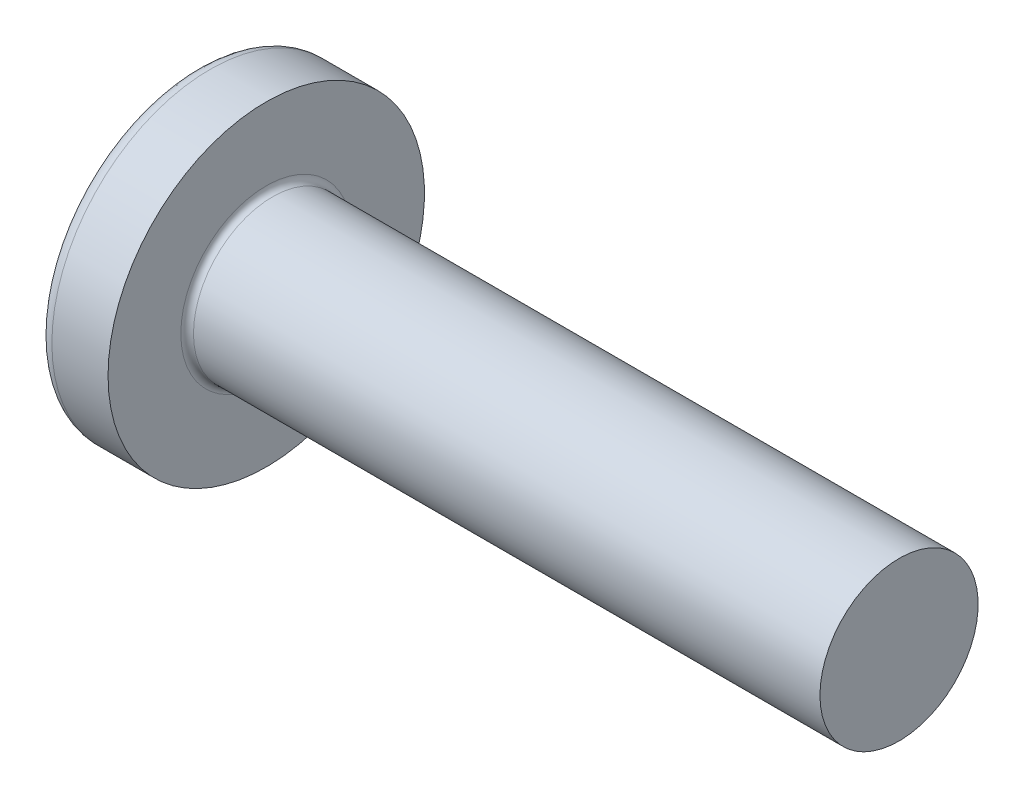
from build123d import *

# Parameters (mm, degrees)
FILLET1_R    = 0.4
SKETCH3_W    = 2.16
SKETCH3_H    = 9.9
SKETCH4_W    = 2.16
SKETCH4_H    = 4.22614225
RECPAT_COUNT = 2
RECPAT_ANGLE = 90


with BuildPart() as part:
    # BodySke → Base-Revolve (revolve)
    with BuildSketch(Plane.XY):
        with BuildLine():
            Line((7.5, 5), (7.5, 10))
            Line((7.5, 10), (3.950103735, 10))
            ThreePointArc((3.950103735, 10), (3.548946469, 9.905650574), (3.231897997, 9.642384106))
            ThreePointArc((3.231897997, 9.642384106), (0.82947542, 5.084799306), (0, 0))
            Line((0, 0), (47.5, 0))
            Line((47.5, 0), (47.5, 5))
            Line((47.5, 5), (7.5, 5))
        make_face()
    revolve(axis=Axis((-25.4, 0, 0), (1, 0, 0)))

    # Fillet1
    fillet1_edges = [part.edges().sort_by_distance(p)[0] for p in [
        (7.5, -5, 0),
    ]]
    fillet(fillet1_edges, radius=FILLET1_R)

    # Sketch3 → Recess section 0
    with BuildSketch(Plane(origin=(0, 0, 0), x_dir=(0, 0, -1), z_dir=(1, 0, 0))):
        Rectangle(SKETCH3_W, SKETCH3_H)
    # Sketch4 → Recess section 1
    with BuildSketch(Plane(origin=(5.69, 0, 0), x_dir=(0, 0, -1), z_dir=(1, 0, 0))):
        Rectangle(SKETCH4_W, SKETCH4_H)
    recess = loft(mode=Mode.SUBTRACT)

    # RecPat: Recess ×2 about axis
    recpat_axis = Axis((0, 0, 0), (1, 0, 0))
    for i in range(1, RECPAT_COUNT):
        add(recess.rotate(recpat_axis, i * RECPAT_ANGLE / (RECPAT_COUNT - 1)), mode=Mode.SUBTRACT)

    # RecCorSke → RecessCore (revolve, cut)
    with BuildSketch(Plane.XY):
        Polygon((0, 0), (0, 2.32838356), (5.69, 1.9305), (6.317257474, 0), align=None)
    revolve(axis=Axis((-3.175, 0, 0), (1, 0, 0)), mode=Mode.SUBTRACT)


solid = part.part
